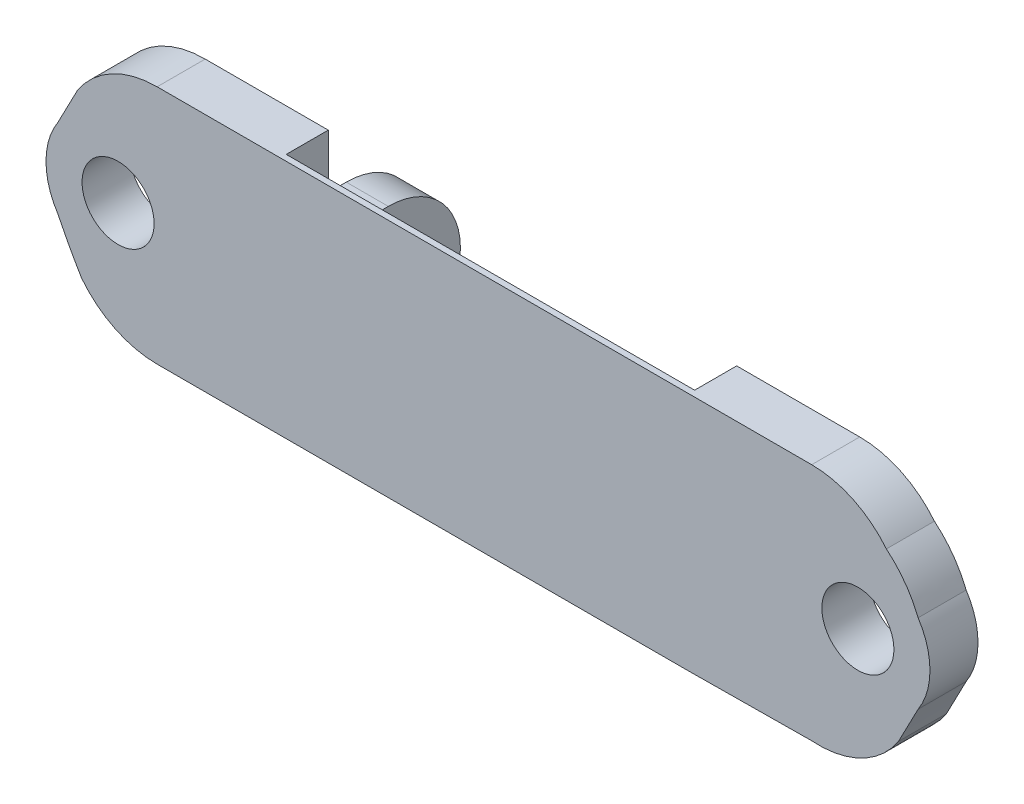
from build123d import *

# Parameters (mm, degrees)
SKETCH1_R           = 3.000027903
BOSS_EXTRUDE1_DEPTH = 4
BOSS_EXTRUDE4_DEPTH = 3.5
BOSS_EXTRUDE6_DEPTH = 34
BOSS_EXTRUDE7_DEPTH = 3.5
SKETCH8_R           = 3.000027903
BOSS_EXTRUDE8_DEPTH = 4


with BuildPart() as part:
    # Sketch1 → Boss-Extrude1 (new body)
    with BuildSketch(Plane.XY):
        with BuildLine():
            ThreePointArc((-35.515, 3.29389), (-36.500003461, -2e-06), (-35.515, -3.293894))
            add(Edge.make_bspline(
                [(-35.515, -3.293894), (-34.604438991, -5.156956918), (-33.54048, -6.937562)],
                knots=[0, 0, 0, 1, 1, 1], degree=2))
            ThreePointArc((-33.54048, -6.937562), (-30.745960827, -9.193764608), (-27.245993386, -10.000000017))
            Line((-27.245993386, -10.000000017), (-16.999993386, -10.000000017))
            Line((-16.999993386, -10.000000017), (-16.999993386, 9.999999983))
            Line((-16.999993386, 9.999999983), (-27.245993386, 9.999999983))
            ThreePointArc((-27.245993386, 9.999999983), (-31.011968955, 9.057189861), (-33.875915, 6.4362595))
            add(Edge.make_bspline(
                [(-33.875915, 6.4362595), (-34.671605619, 4.852572547), (-35.515, 3.29389)],
                knots=[0, 0, 0, 1, 1, 1], degree=2))
        make_face()
        with Locations((-30.500046711, -2e-06)):
            Circle(SKETCH1_R, mode=Mode.SUBTRACT)
    extrude(amount=BOSS_EXTRUDE1_DEPTH)

    # Sketch5 → Boss-Extrude4 (add)
    with BuildSketch(Plane(origin=(-16.999993386, 0, 0), x_dir=(0, 0, -1), z_dir=(1, 0, 0))):
        with BuildLine():
            Line((4.999999299, 2.000001386), (0, 2.000001386))
            Line((0, 2.000001386), (0, -10.000000017))
            Line((0, -10.000000017), (4.999999299, -10.000000017))
            ThreePointArc((4.999999299, -10.000000017), (9.242640482, -8.242640499), (11, -3.999999316))
            ThreePointArc((11, -3.999999316), (9.242640482, 0.242641867), (4.999999299, 2.000001386))
        make_face()
        with BuildLine():
            ThreePointArc((5.745163587, -1.412519358), (7.746056235, -2.073529521), (8.6, -3.999999316))
            ThreePointArc((8.6, -3.999999316), (8.009825654, -5.649423344), (6.507230229, -6.550041118))
            ThreePointArc((6.507230229, -6.550041118), (3.428142195, -4.381492167), (5.745163587, -1.412519358))
        make_face(mode=Mode.SUBTRACT)
    extrude(amount=-BOSS_EXTRUDE4_DEPTH)

    # Sketch5_4 → Boss-Extrude6 (add)
    with BuildSketch(Plane(origin=(-16.999993386, 0, 0), x_dir=(0, 0, -1), z_dir=(1, 0, 0))):
        Polygon((-2, -2.292812017), (-3.500601, 9.999999983), (-4, 9.999999983), (-4, -10.000000017), (-2, -10.000000017), align=None)
    extrude(amount=BOSS_EXTRUDE6_DEPTH)



with BuildPart() as body_2:
    # Sketch7 → Boss-Extrude7 (new body)
    with BuildSketch(Plane(origin=(17.000006614, 0, 0), x_dir=(0, 0, -1), z_dir=(1, 0, 0))):
        with BuildLine():
            Line((4.999999299, 1.98580143), (0, 1.98580143))
            Line((0, 1.98580143), (0, -10.014199973))
            Line((0, -10.014199973), (4.999999299, -10.014199973))
            ThreePointArc((4.999999299, -10.014199973), (9.242640482, -8.256840455), (11, -4.014199272))
            ThreePointArc((11, -4.014199272), (9.242640482, 0.228441911), (4.999999299, 1.98580143))
        make_face()
        with BuildLine():
            ThreePointArc((5.745163587, -1.426719314), (7.746056235, -2.087729477), (8.6, -4.014199272))
            ThreePointArc((8.6, -4.014199272), (8.009825654, -5.6636233), (6.507230229, -6.564241074))
            ThreePointArc((6.507230229, -6.564241074), (3.428142195, -4.395692123), (5.745163587, -1.426719314))
        make_face(mode=Mode.SUBTRACT)
    extrude(amount=BOSS_EXTRUDE7_DEPTH)


with BuildPart() as part_1:
    add(part.part)

    add(body_2.part)  # Boss-Extrude8 merges body 2
    # Sketch8 → Boss-Extrude8 (add)
    with BuildSketch(Plane.XY.offset(4)):
        with BuildLine():
            Line((17.000006614, -10.000000017), (27.246006614, -9.904922539))
            ThreePointArc((27.246006614, -9.904922539), (31.344343382, -9.110808917), (34.467826641, -6.341182039))
            add(Edge.make_bspline(
                [(34.467826641, -6.341182039), (35.26351726, -4.757495086), (36.106911641, -3.198812539)],
                knots=[0, 0, 0, 1, 1, 1], degree=2))
            ThreePointArc((36.106911641, -3.198812539), (37.091915102, 0.095079461), (36.106911641, 3.388971461))
            add(Edge.make_bspline(
                [(36.106911641, 3.388971461), (35.255873472, 5.530984122), (33.464737791, 7.032639461)],
                knots=[0, 0, 0, 1, 1, 1], degree=2))
            ThreePointArc((33.464737791, 7.032639461), (30.691215095, 9.22014949), (27.246006614, 9.999999983))
            Line((27.246006614, 9.999999983), (17.000006614, 9.999999983))
            Line((17.000006614, 9.999999983), (17.000006614, -8.622062624))
            Line((17.000006614, -8.622062624), (17.000006614, -10.000000017))
        make_face()
        with Locations((31.091958352, 0.095079461)):
            Circle(SKETCH8_R, mode=Mode.SUBTRACT)
    extrude(amount=-BOSS_EXTRUDE8_DEPTH)


solid = part_1.part
